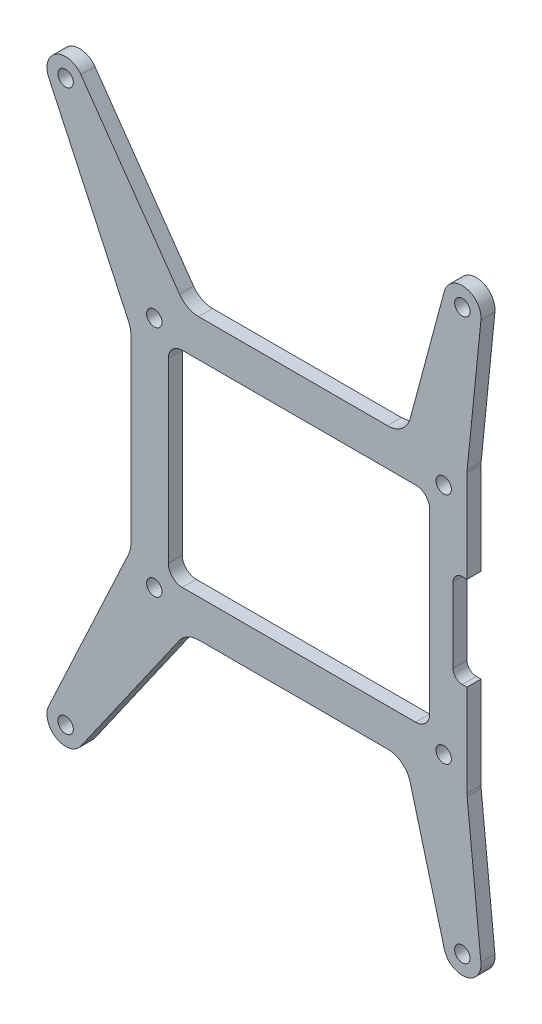
from build123d import *

# Parameters (mm, degrees)
SKETCH_1_W          = 72
SKETCH_1_H          = 60
SKETCH_1_R          = 1.65
SKETCH_1_W_2        = 56
SKETCH_1_H_2        = 44
EXTRUDE_1_DEPTH     = 3
FILLET_1_R          = 3
SKETCH_2_R          = 1.65
EXTRUDE_2_DEPTH     = 3
FILLET_2_R          = 5
FILLET_3_R          = 6
SKETCH_3_W          = 6
SKETCH_3_H          = 20
CUT_EXTRUDE_1_DEPTH = 4
FILLET_4_R          = 2


with BuildPart() as part:
    # 草图1 → 凸台-拉伸1 (new body)
    with BuildSketch(Plane.XY):
        Rectangle(SKETCH_1_W, SKETCH_1_H)
        with Locations((31, -25)):
            Circle(SKETCH_1_R, mode=Mode.SUBTRACT)
        with Locations((31, 25)):
            Circle(SKETCH_1_R, mode=Mode.SUBTRACT)
        with Locations((-31, 25)):
            Circle(SKETCH_1_R, mode=Mode.SUBTRACT)
        with Locations((-31, -25)):
            Circle(SKETCH_1_R, mode=Mode.SUBTRACT)
        Rectangle(SKETCH_1_W_2, SKETCH_1_H_2, mode=Mode.SUBTRACT)
    extrude(amount=EXTRUDE_1_DEPTH)

    # 圆角1
    fillet_1_edges = [part.edges().sort_by_distance(p)[0] for p in [
        (-28, 22, 1.5),
        (-28, -22, 1.5),
        (28, -22, 1.5),
        (28, 22, 1.5),
    ]]
    fillet(fillet_1_edges, radius=FILLET_1_R)

    # 草图2 → 凸台-拉伸2 (add)
    with BuildSketch(Plane.XY.offset(3)):
        with BuildLine():
            Line((-46.723391823, 62.294305745), (-24.110675499, 30))
            Line((-24.110675499, 30), (-36, 30))
            Line((-36, 30), (-36, 20.51209678))
            Line((-36, 20.51209678), (-53.625231148, 58.309526953))
            ThreePointArc((-53.625231148, 58.309526953), (-52, 63.464101615), (-46.723391823, 62.294305745))
        make_face()
        with Locations((-50, 60)):
            Circle(SKETCH_2_R, mode=Mode.SUBTRACT)
        with BuildLine():
            Line((-46.723391823, -62.294305745), (-24.110675499, -30))
            Line((-24.110675499, -30), (-36, -30))
            Line((-36, -30), (-36, -20.51209678))
            Line((-36, -20.51209678), (-53.625231148, -58.309526953))
            ThreePointArc((-53.625231148, -58.309526953), (-52, -63.464101615), (-46.723391823, -62.294305745))
        make_face()
        with Locations((-50, -60)):
            Circle(SKETCH_2_R, mode=Mode.SUBTRACT)
        with BuildLine():
            Line((31.136296695, 61.03527618), (22.820419505, 30))
            Line((22.820419505, 30), (36, 30))
            Line((36, 30), (38.979882295, 59.59932941))
            ThreePointArc((38.979882295, 59.59932941), (35.720319493, 63.934607964), (31.136296695, 61.03527618))
        make_face()
        with Locations((35, 60)):
            Circle(SKETCH_2_R, mode=Mode.SUBTRACT)
        with BuildLine():
            Line((38.979882295, -59.59932941), (36, -30))
            Line((36, -30), (22.820419505, -30))
            Line((22.820419505, -30), (31.136296695, -61.03527618))
            ThreePointArc((31.136296695, -61.03527618), (35.720319493, -63.934607964), (38.979882295, -59.59932941))
        make_face()
        with Locations((35, -60)):
            Circle(SKETCH_2_R, mode=Mode.SUBTRACT)
    extrude(amount=-EXTRUDE_2_DEPTH)

    # 圆角2
    fillet_2_edges = [part.edges().sort_by_distance(p)[0] for p in [
        (22.820419505, -30, 1.5),
        (22.820419505, 30, 1.5),
        (-24.110675499, 30, 1.5),
        (36, 30, 1.5),
        (36, -30, 1.5),
        (-24.110675499, -30, 1.5),
    ]]
    fillet(fillet_2_edges, radius=FILLET_2_R)

    # 圆角3
    fillet_3_edges = [part.edges().sort_by_distance(p)[0] for p in [
        (-36, 20.51209678, 1.5),
        (-36, -20.51209678, 1.5),
    ]]
    fillet(fillet_3_edges, radius=FILLET_3_R)

    # 草图3 → 切除-拉伸1 (cut, through all)
    with BuildSketch(Plane.XY.offset(3)):
        with Locations((36, 0)):
            Rectangle(SKETCH_3_W, SKETCH_3_H)
    extrude(amount=-CUT_EXTRUDE_1_DEPTH, mode=Mode.SUBTRACT)

    # 圆角4
    fillet_4_edges = [part.edges().sort_by_distance(p)[0] for p in [
        (33, 10, 1.5),
        (33, -10, 1.5),
    ]]
    fillet(fillet_4_edges, radius=FILLET_4_R)


solid = part.part
